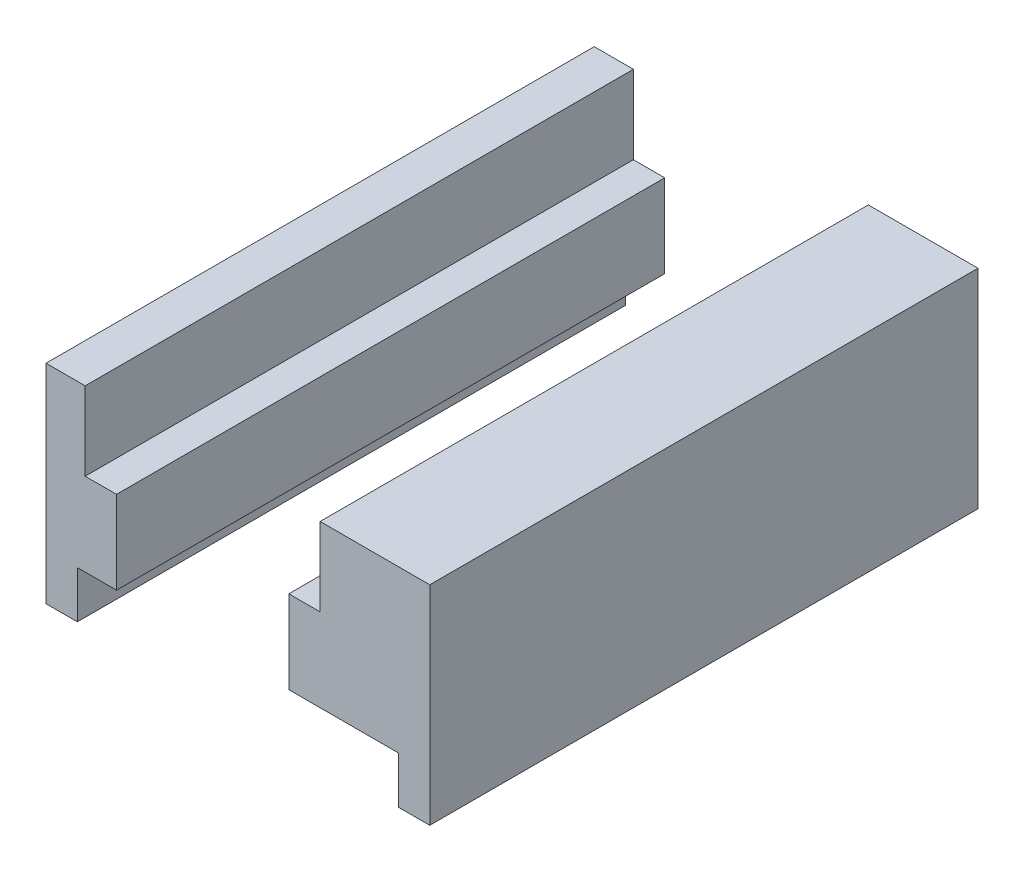
from build123d import *

# Parameters (mm, degrees)
BOSS_EXTRUDE3_DEPTH   = 35
BOSS_EXTRUDE3_2_DEPTH = 35


with BuildPart() as part:
    # Sketch2 → Boss-Extrude3 (new body)
    with BuildSketch(Plane.XY):
        Polygon((10.25, 0), (10.25, 3), (3.25, 3), (3.25, 8.3), (5.25, 8.3), (5.25, 13.3), (12.25, 13.3), (12.25, 0), align=None)
    extrude(amount=BOSS_EXTRUDE3_DEPTH)


with BuildPart() as body_2:
    # Sketch2 → Boss-Extrude3 2 (new body)
    with BuildSketch(Plane.XY):
        Polygon((-7.75, 8.3), (-7.75, 3), (-10.25, 3), (-10.25, 0), (-12.25, 0), (-12.25, 13.3), (-9.75, 13.3), (-9.75, 8.3), align=None)
    extrude(amount=BOSS_EXTRUDE3_2_DEPTH)


solid = Compound([part.part, body_2.part])
